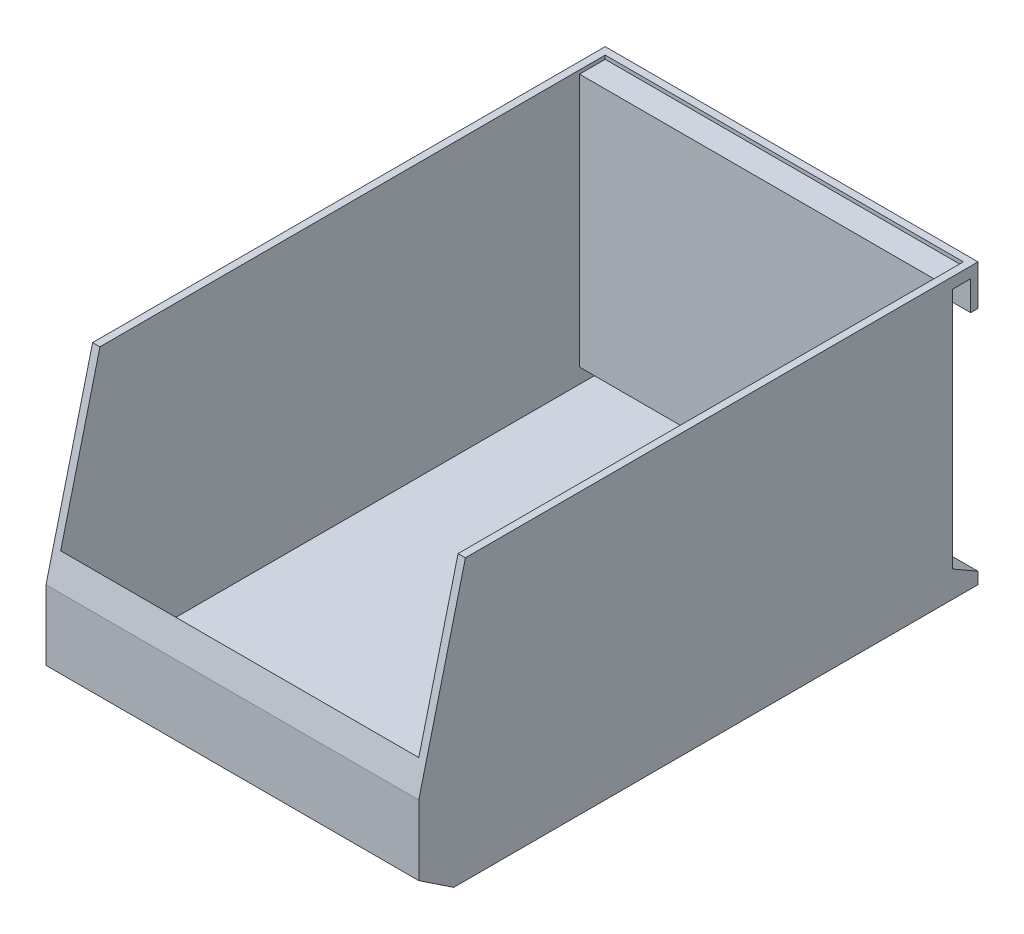
from build123d import *

# Parameters (mm, degrees)
SKETCH1_W           = 101.6
SKETCH1_H           = 152.4
BOSS_EXTRUDE1_DEPTH = 76.2
CUT_EXTRUDE1_DEPTH  = 102.6
CUT_EXTRUDE2_DEPTH  = 102.6
SHELL1_T            = -2


with BuildPart() as part:
    # Sketch1 → Boss-Extrude1 (new body)
    with BuildSketch(Plane(origin=(0, 0, 0), x_dir=(1, 0, 0), z_dir=(0, 1, 0))):
        Rectangle(SKETCH1_W, SKETCH1_H)
    extrude(amount=BOSS_EXTRUDE1_DEPTH)

    # Sketch2 → Cut-Extrude1 (cut, through all)
    with BuildSketch(Plane(origin=(50.8, 0, 0), x_dir=(0, 0, -1), z_dir=(1, 0, 0))):
        Polygon((-63.5, 76.2), (-76.2, 25.4), (-76.2, 76.2), align=None)
        Polygon((-76.2, 6.35), (-76.2, 0), (-66.675, 0), align=None)
    extrude(amount=-CUT_EXTRUDE1_DEPTH, mode=Mode.SUBTRACT)

    # Sketch3 → Cut-Extrude2 (cut, through all)
    with BuildSketch(Plane(origin=(50.8, 0, 0), x_dir=(0, 0, -1), z_dir=(1, 0, 0))):
        Polygon((69.2, 7.216451884), (69.2, 65.2), (69.2, 73.2), (74.2, 73.2), (74.2, 65.2), (76.2, 65.2), (76.2, 3.175), align=None)
    extrude(amount=-CUT_EXTRUDE2_DEPTH, mode=Mode.SUBTRACT)

    # Shell1
    shell1_openings = [part.faces().sort_by_distance(p)[0] for p in [
        (0, 76.2, -6.35),
        (0, 50.8, 69.85),
    ]]
    offset(amount=SHELL1_T, openings=shell1_openings, kind=Kind.INTERSECTION)


solid = part.part
